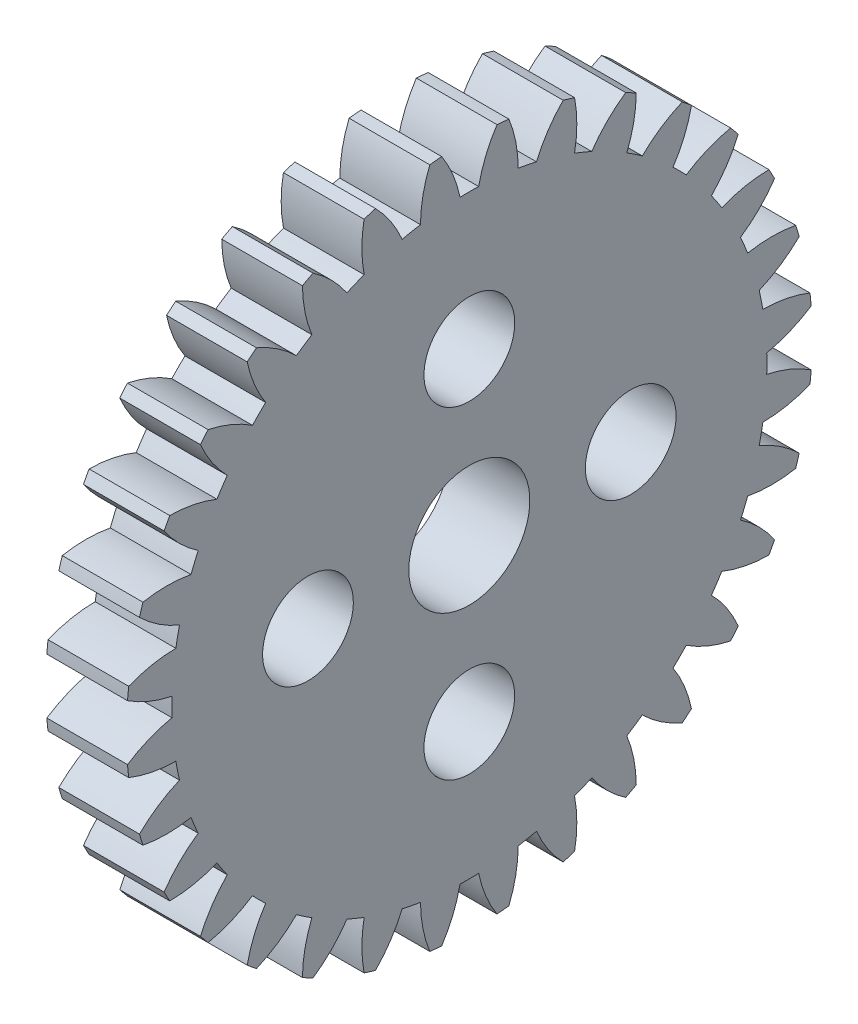
from build123d import *

# Parameters (mm, degrees)
BASPROSKE_W          = 4
BASPROSKE_H          = 17
TOOTHCUT_DEPTH       = 25.372115214
TEETHCUTS_COUNT      = 32
TEETHCUTS_ANGLE      = 348.75
BORSKE_R             = 3
BORE_DEPTH           = 50.0000508
M4_CLEARANCE_HOLE1_D = 4.5
CIRPATTERN1_COUNT    = 4


with BuildPart() as part:
    # BasProSke → Base-Revolve (revolve)
    with BuildSketch(Plane(origin=(0, 0, 0), x_dir=(1, 0, 0), z_dir=(0, 1, 0)), mode=Mode.PRIVATE) as base_revolve_sk:
        with Locations((2, 8.5)):
            Rectangle(BASPROSKE_W, BASPROSKE_H)
    revolve(base_revolve_sk.sketch.rotate(Axis((-10, 0, 0), (1, 0, 0)), 180), axis=Axis((-10, 0, 0), (1, 0, 0)))

    # TooCutSke → ToothCut (cut, through all)
    with BuildSketch(Plane(origin=(0, 0, 0), x_dir=(0, 0, -1), z_dir=(1, 0, 0))):
        with BuildLine():
            ThreePointArc((0.462036907, 14.741761187), (0, 14.749), (-0.462036907, 14.741761187))
            ThreePointArc((-0.462036907, 14.741761187), (-0.81854142, 15.899240468), (-1.386721275, 16.9688317))
            ThreePointArc((-1.386721275, 16.9688317), (0, 17.0254), (1.386721275, 16.9688317))
            ThreePointArc((1.386721275, 16.9688317), (0.81854142, 15.899240468), (0.462036907, 14.741761187))
        make_face()
    toothcut = extrude(amount=TOOTHCUT_DEPTH, mode=Mode.SUBTRACT)

    # TeethCuts: ToothCut ×32 about axis
    teethcuts_axis = Axis((-10, 0, 0), (1, 0, 0))
    for i in range(1, TEETHCUTS_COUNT):
        add(toothcut.rotate(teethcuts_axis, i * TEETHCUTS_ANGLE / (TEETHCUTS_COUNT - 1)), mode=Mode.SUBTRACT)

    # BorSke → Bore (cut, symmetric)
    with BuildSketch(Plane(origin=(0, 0, 0), x_dir=(0, 0, -1), z_dir=(1, 0, 0))):
        with Locations(Location((0, 0, 0), (0, 0, 180))):
            Circle(BORSKE_R)
    extrude(amount=BORE_DEPTH, both=True, mode=Mode.SUBTRACT)

    # M4 Clearance Hole1 (through all)
    with Locations(Plane(origin=(4, 0, 0), x_dir=(0, 0, -1), z_dir=(1, 0, 0))):
        with Locations((0, 8)):
            m4_clearance_hole1 = Hole(M4_CLEARANCE_HOLE1_D / 2)

    # CirPattern1: M4 Clearance Hole1 ×4 about axis
    cirpattern1_axis = Axis((0, 0, 0), (1, 0, 0))
    for i in range(1, CIRPATTERN1_COUNT):
        add(m4_clearance_hole1.rotate(cirpattern1_axis, i * 360 / CIRPATTERN1_COUNT), mode=Mode.SUBTRACT)


solid = part.part
